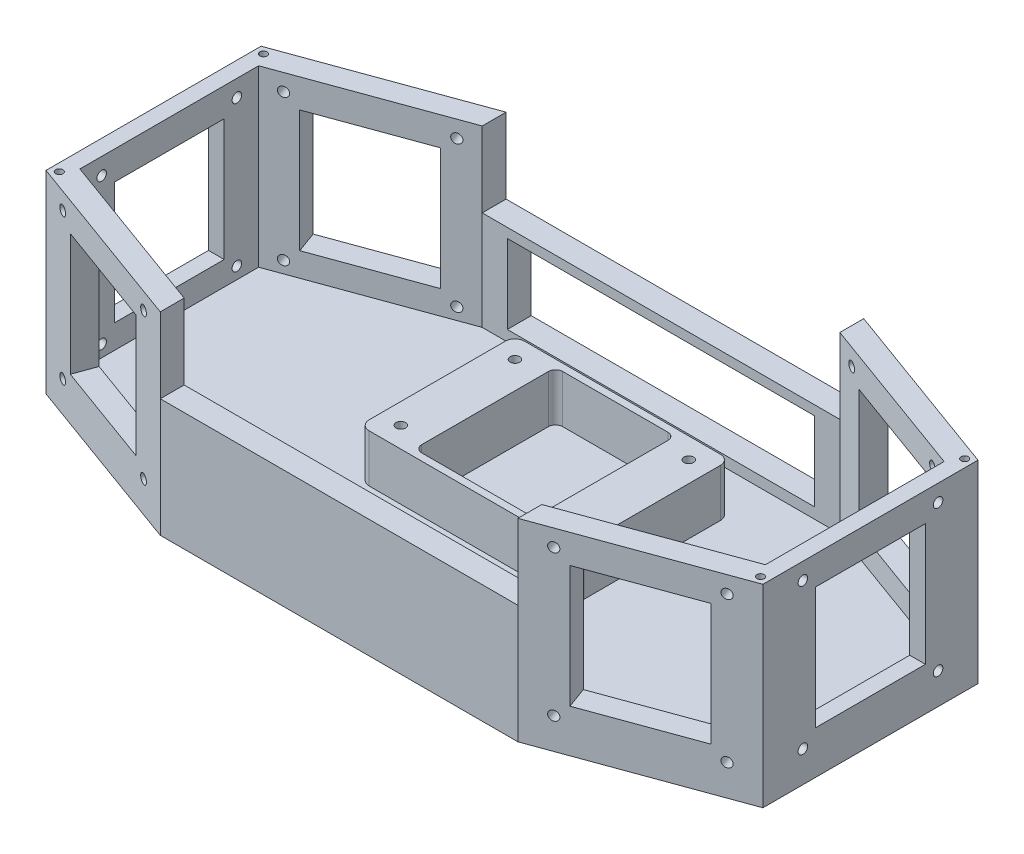
from build123d import *

# Parameters (mm, degrees)
BOSS_EXTRUDE1_DEPTH     = 8
SKETCH2_W               = 10.5
SKETCH2_H               = 10
BOSS_EXTRUDE2_DEPTH     = 37.5
SKETCH4_W               = 128.649180674
SKETCH4_H               = 10
BOSS_EXTRUDE4_DEPTH     = 4.5
BOSS_EXTRUDE5_DEPTH     = 10
SKETCH6_W               = 149.649180674
SKETCH6_H               = 10
BOSS_EXTRUDE6_DEPTH     = 4
SKETCH7_R               = 2
CUT_EXTRUDE1_DEPTH      = 9.396926
MIRROR2_COPY_1_SKETCH_R = 2
MIRROR2_COPY_1_DEPTH    = 9.396926
SKETCH8_R               = 2
CUT_EXTRUDE2_DEPTH      = 75.17541
BOSS_EXTRUDE8_DEPTH     = 63
SKETCH10_R              = 2
CUT_EXTRUDE3_DEPTH      = 9.396926
MIRROR5_COPY_1_SKETCH_R = 2
MIRROR5_COPY_1_DEPTH    = 9.396926
SKETCH11_R              = 2
CUT_EXTRUDE4_DEPTH      = 75.17541
SKETCH12_W              = 6.577848346
SKETCH12_H              = 46
BOSS_EXTRUDE9_DEPTH     = 12
BOSS_EXTRUDE10_DEPTH    = 20
SKETCH14_R              = 2
CUT_EXTRUDE5_DEPTH      = 10
SKETCH15_W              = 149.649180674
SKETCH15_H              = 10
BOSS_EXTRUDE11_DEPTH    = 41.5
SKETCH17_R              = 1.5
CUT_EXTRUDE6_DEPTH      = 10


with BuildPart() as part:
    # Sketch1 → Boss-Extrude1 (new body)
    with BuildSketch(Plane(origin=(0, 0, 0), x_dir=(1, 0, 0), z_dir=(0, 1, 0))):
        Polygon((-150, 45), (-150, -45), (-74.824590337, -72.361611466), (74.824590337, -72.361611466), (150, -45), (150, 45), (74.824590337, 72.361611466), (-74.824590337, 72.361611466), align=None)
    extrude(amount=BOSS_EXTRUDE1_DEPTH)

    # Sketch2 → Boss-Extrude2 (add)
    with BuildSketch(Plane(origin=(0, 8, 0), x_dir=(1, 0, 0), z_dir=(0, 1, 0))):
        with Locations((69.574590337, 67.361611466)):
            Rectangle(SKETCH2_W, SKETCH2_H)
        with Locations((-69.574590337, 67.361611466)):
            Rectangle(SKETCH2_W, SKETCH2_H)
    extrude(amount=BOSS_EXTRUDE2_DEPTH)

    # Sketch4 → Boss-Extrude4 (add)
    with BuildSketch(Plane(origin=(0, 8, 0), x_dir=(1, 0, 0), z_dir=(0, 1, 0))):
        with Locations((0, 67.361611466)):
            Rectangle(SKETCH4_W, SKETCH4_H)
    extrude(amount=BOSS_EXTRUDE4_DEPTH)

    # Sketch5 → Boss-Extrude5 (add)
    with BuildSketch(Plane(origin=(0, 8, 0), x_dir=(1, 0, 0), z_dir=(0, 1, 0))):
        Polygon((-74.824590337, 62.361611466), (-87.040594407, 57.915349603), (-140.603073792, 38.420201433), (-143.422151654, 37.394141003), (-143.422151654, -37.394141003), (-140.603073792, -38.420201433), (-87.040594407, -57.915349603), (-74.824590337, -62.361611466), (-74.824590337, -72.361611466), (-150, -45), (-150, 45), (-74.824590337, 72.361611466), align=None)
        Polygon((150, 45), (150, -45), (74.824590337, -72.361611466), (74.824590337, -62.361611466), (87.040594407, -57.915349603), (140.603073792, -38.420201433), (143.422151654, -37.394141003), (143.422151654, 37.394141003), (140.603073792, 38.420201433), (87.040594407, 57.915349603), (74.824590337, 62.361611466), (74.824590337, 72.361611466), align=None)
    extrude(amount=BOSS_EXTRUDE5_DEPTH)

    # Sketch6 → Boss-Extrude6 (add)
    with BuildSketch(Plane(origin=(0, 45.5, 0), x_dir=(1, 0, 0), z_dir=(0, 1, 0))):
        with Locations((0, 67.361611466)):
            Rectangle(SKETCH6_W, SKETCH6_H)
    extrude(amount=BOSS_EXTRUDE6_DEPTH)

    # Sketch7 → Cut-Extrude1 (cut)
    with BuildSketch(Plane(origin=(32.009387984, 0, -87.945070697), x_dir=(-0.939692621, 0, -0.342020143), z_dir=(0.342020143, 0, -0.939692621))):
        with Locations((-113.852986668, 13)):
            Circle(SKETCH7_R)
        with Locations((-57.272986668, 13)):
            Circle(SKETCH7_R)
    cut_extrude1 = extrude(amount=-CUT_EXTRUDE1_DEPTH, mode=Mode.SUBTRACT)

    # Mirror1: Cut-Extrude1 across plane
    add(cut_extrude1.mirror(Plane(origin=(0, 0, 0), x_dir=(0, 0, 1), z_dir=(1, 0, 0))), mode=Mode.SUBTRACT)

    # Mirror2: Cut-Extrude1 across plane
    add(cut_extrude1.mirror(Plane(origin=(0, 0, 0), x_dir=(1, 0, 0), z_dir=(0, 0, -1))), mode=Mode.SUBTRACT)

    # Mirror2 copy 1 sketch → Mirror2 copy 1 (cut)
    with BuildSketch(Plane(origin=(-32.009387984, 0, 87.945070697), x_dir=(0.939692621, 0, 0.342020143), z_dir=(-0.342020143, 0, 0.939692621))):
        with Locations((-113.852986668, 13)):
            Circle(MIRROR2_COPY_1_SKETCH_R)
        with Locations((-57.272986668, 13)):
            Circle(MIRROR2_COPY_1_SKETCH_R)
    extrude(amount=-MIRROR2_COPY_1_DEPTH, mode=Mode.SUBTRACT)

    # Sketch8 → Cut-Extrude2 (cut)
    with BuildSketch(Plane(origin=(150, 0, 0), x_dir=(0, 0, -1), z_dir=(1, 0, 0))):
        with Locations((-28.29, 13)):
            Circle(SKETCH8_R)
        with Locations((28.29, 13)):
            Circle(SKETCH8_R)
    cut_extrude2 = extrude(amount=-CUT_EXTRUDE2_DEPTH, mode=Mode.SUBTRACT)

    # Mirror3: Cut-Extrude2 across plane
    add(cut_extrude2.mirror(Plane(origin=(0, 0, 0), x_dir=(0, 0, 1), z_dir=(1, 0, 0))), mode=Mode.SUBTRACT)

    # Sketch9 → Boss-Extrude8 (add)
    with BuildSketch(Plane(origin=(0, 18, 0), x_dir=(1, 0, 0), z_dir=(0, 1, 0))):
        Polygon((143.422151654, 23), (150, 23), (150, 45), (134.025225447, 50.814342437), (130.811287398, 41.984120221), (143.422151654, 37.394141003), align=None)
        Polygon((74.824590337, 72.361611466), (90.79936489, 66.54726903), (87.585426842, 57.717046814), (74.824590337, 62.361611466), align=None)
        Polygon((-74.824590337, 62.361611466), (-74.824590337, 72.361611466), (-90.79936489, 66.54726903), (-87.585426842, 57.717046814), align=None)
        Polygon((-143.422151654, 37.394141003), (-143.422151654, 23), (-150, 23), (-150, 45), (-134.025225447, 50.814342437), (-130.811287398, 41.984120221), align=None)
        Polygon((143.422151654, -37.394141003), (143.422151654, -23), (150, -23), (150, -45), (134.025225447, -50.814342437), (130.811287398, -41.984120221), align=None)
        Polygon((-143.422151654, -23), (-150, -23), (-150, -45), (-134.025225447, -50.814342437), (-130.811287398, -41.984120221), (-143.422151654, -37.394141003), align=None)
        Polygon((-74.824590337, -72.361611466), (-90.79936489, -66.54726903), (-87.585426842, -57.717046814), (-74.824590337, -62.361611466), align=None)
        Polygon((74.824590337, -62.361611466), (74.824590337, -72.361611466), (90.79936489, -66.54726903), (87.585426842, -57.717046814), align=None)
    extrude(amount=BOSS_EXTRUDE8_DEPTH)

    # Sketch10 → Cut-Extrude3 (cut)
    with BuildSketch(Plane(origin=(32.009387984, 0, -87.945070697), x_dir=(-0.939692621, 0, -0.342020143), z_dir=(0.342020143, 0, -0.939692621))):
        with Locations((-113.852986668, 74)):
            Circle(SKETCH10_R)
        with Locations((-57.272986668, 74)):
            Circle(SKETCH10_R)
    cut_extrude3 = extrude(amount=-CUT_EXTRUDE3_DEPTH, mode=Mode.SUBTRACT)

    # Mirror4: Cut-Extrude3 across plane
    add(cut_extrude3.mirror(Plane(origin=(0, 0, 0), x_dir=(0, 0, 1), z_dir=(1, 0, 0))), mode=Mode.SUBTRACT)

    # Mirror5: Cut-Extrude3 across plane
    add(cut_extrude3.mirror(Plane(origin=(0, 0, 0), x_dir=(1, 0, 0), z_dir=(0, 0, -1))), mode=Mode.SUBTRACT)

    # Mirror5 copy 1 sketch → Mirror5 copy 1 (cut)
    with BuildSketch(Plane(origin=(-32.009387984, 0, 87.945070697), x_dir=(0.939692621, 0, 0.342020143), z_dir=(-0.342020143, 0, 0.939692621))):
        with Locations((-113.852986668, 74)):
            Circle(MIRROR5_COPY_1_SKETCH_R)
        with Locations((-57.272986668, 74)):
            Circle(MIRROR5_COPY_1_SKETCH_R)
    extrude(amount=-MIRROR5_COPY_1_DEPTH, mode=Mode.SUBTRACT)

    # Sketch11 → Cut-Extrude4 (cut)
    with BuildSketch(Plane(origin=(150, 0, 0), x_dir=(0, 0, -1), z_dir=(1, 0, 0))):
        with Locations((-28.29, 74)):
            Circle(SKETCH11_R)
        with Locations((28.29, 74)):
            Circle(SKETCH11_R)
    cut_extrude4 = extrude(amount=-CUT_EXTRUDE4_DEPTH, mode=Mode.SUBTRACT)

    # Mirror6: Cut-Extrude4 across plane
    add(cut_extrude4.mirror(Plane(origin=(0, 0, 0), x_dir=(0, 0, 1), z_dir=(1, 0, 0))), mode=Mode.SUBTRACT)

    # Sketch12 → Boss-Extrude9 (add)
    with BuildSketch(Plane(origin=(0, 81, 0), x_dir=(1, 0, 0), z_dir=(0, 1, 0))):
        Polygon((130.811287398, 41.984120221), (87.585426842, 57.717046814), (90.79936489, 66.54726903), (134.025225447, 50.814342437), align=None)
        with Locations((146.711075827, 0)):
            Rectangle(SKETCH12_W, SKETCH12_H)
        Polygon((134.025225447, -50.814342437), (130.811287398, -41.984120221), (87.585426842, -57.717046814), (90.79936489, -66.54726903), align=None)
        Polygon((-130.811287398, -41.984120221), (-87.585426842, -57.717046814), (-90.79936489, -66.54726903), (-134.025225447, -50.814342437), align=None)
        with Locations((-146.711075827, 0)):
            Rectangle(SKETCH12_W, SKETCH12_H)
        Polygon((-134.025225447, 50.814342437), (-130.811287398, 41.984120221), (-87.585426842, 57.717046814), (-90.79936489, 66.54726903), align=None)
    extrude(amount=-BOSS_EXTRUDE9_DEPTH)

    # Sketch13 → Boss-Extrude10 (add)
    with BuildSketch(Plane(origin=(0, 8, 0), x_dir=(1, 0, 0), z_dir=(0, 1, 0))):
        with BuildLine():
            Line((-41, 46.231611466), (-29, 46.231611466))
            Line((-29, 46.231611466), (29, 46.231611466))
            Line((29, 46.231611466), (41, 46.231611466))
            ThreePointArc((41, 46.231611466), (43.828427125, 45.060038591), (45, 42.231611466))
            Line((45, 42.231611466), (45, -14.768388534))
            ThreePointArc((45, -14.768388534), (43.828427125, -17.596815659), (41, -18.768388534))
            Line((41, -18.768388534), (29, -18.768388534))
            Line((29, -18.768388534), (-29, -18.768388534))
            Line((-29, -18.768388534), (-41, -18.768388534))
            ThreePointArc((-41, -18.768388534), (-43.828427125, -17.596815659), (-45, -14.768388534))
            Line((-45, -14.768388534), (-45, 42.231611466))
            ThreePointArc((-45, 42.231611466), (-43.828427125, 45.060038591), (-41, 46.231611466))
        make_face()
        with BuildLine():
            Line((-25, 40.231611466), (-25, -12.768388534))
            ThreePointArc((-25, -12.768388534), (-24.121320344, -14.889708878), (-22, -15.768388534))
            Line((-22, -15.768388534), (22, -15.768388534))
            ThreePointArc((22, -15.768388534), (24.121320344, -14.889708878), (25, -12.768388534))
            Line((25, -12.768388534), (25, 40.231611466))
            ThreePointArc((25, 40.231611466), (24.121320344, 42.35293181), (22, 43.231611466))
            Line((22, 43.231611466), (-22, 43.231611466))
            ThreePointArc((-22, 43.231611466), (-24.121320344, 42.35293181), (-25, 40.231611466))
        make_face(mode=Mode.SUBTRACT)
    extrude(amount=BOSS_EXTRUDE10_DEPTH)

    # Sketch14 → Cut-Extrude5 (cut)
    with BuildSketch(Plane(origin=(0, 28, 0), x_dir=(1, 0, 0), z_dir=(0, 1, 0))):
        with Locations((-36.37, 37.606611466)):
            Circle(SKETCH14_R)
        with Locations((-36.37, -10.143388534)):
            Circle(SKETCH14_R)
    cut_extrude5 = extrude(amount=-CUT_EXTRUDE5_DEPTH, mode=Mode.SUBTRACT)

    # Mirror7: Cut-Extrude5 across plane
    add(cut_extrude5.mirror(Plane(origin=(0, 0, 0), x_dir=(0, 0, 1), z_dir=(1, 0, 0))), mode=Mode.SUBTRACT)

    # Sketch15 → Boss-Extrude11 (add)
    with BuildSketch(Plane(origin=(0, 8, 0), x_dir=(1, 0, 0), z_dir=(0, 1, 0))):
        with Locations((0, -67.361611466)):
            Rectangle(SKETCH15_W, SKETCH15_H)
    extrude(amount=BOSS_EXTRUDE11_DEPTH)

    # Sketch17 → Cut-Extrude6 (cut)
    with BuildSketch(Plane(origin=(0, 81, 0), x_dir=(1, 0, 0), z_dir=(0, 1, 0))):
        with Locations((146.723391823, -42.705694255)):
            Circle(SKETCH17_R)
        with Locations((146.723391823, 42.705694255)):
            Circle(SKETCH17_R)
        with Locations((-146.723391823, 42.705694255)):
            Circle(SKETCH17_R)
        with Locations((-146.723391823, -42.705694255)):
            Circle(SKETCH17_R)
    extrude(amount=-CUT_EXTRUDE6_DEPTH, mode=Mode.SUBTRACT)


solid = part.part
